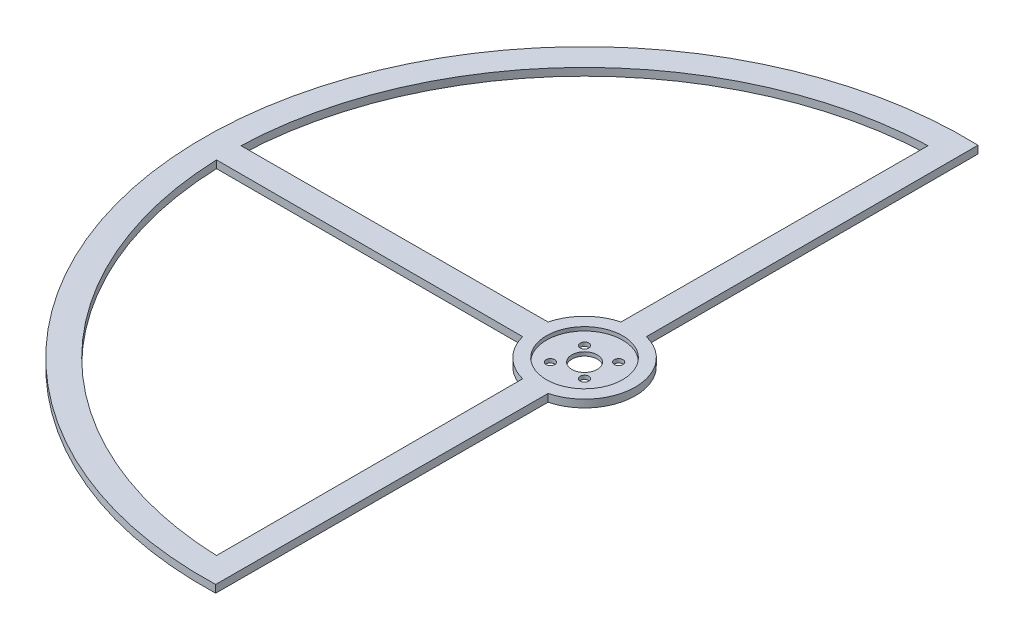
from build123d import *

# Parameters (mm, degrees)
SKETCH1_R           = 5
SKETCH1_R_2         = 1.7
BOSS_EXTRUDE1_DEPTH = 3
SKETCH2_R           = 15
CUT_EXTRUDE1_DEPTH  = 1.5


with BuildPart() as part:
    # Sketch1 → Boss-Extrude1 (new body)
    with BuildSketch(Plane(origin=(0, 0, 0), x_dir=(1, 0, 0), z_dir=(0, 1, 0))):
        with BuildLine():
            Line((5, -19.364916731), (4.6875, -149.926739922))
            ThreePointArc((4.6875, -149.926739922), (-149.999918535, 0.156331529), (5, 149.916643506))
            Line((5, 149.916643506), (5, 19.364916731))
            ThreePointArc((5, 19.364916731), (20, 0), (5, -19.364916731))
        make_face()
        Circle(SKETCH1_R, mode=Mode.SUBTRACT)
        with Locations((-5.656854249, 5.656854249)):
            Circle(SKETCH1_R_2, mode=Mode.SUBTRACT)
        with Locations((5.656854249, -5.656854249)):
            Circle(SKETCH1_R_2, mode=Mode.SUBTRACT)
        with Locations((6.717514421, 6.717514421)):
            Circle(SKETCH1_R_2, mode=Mode.SUBTRACT)
        with Locations((-6.717514421, -6.717514421)):
            Circle(SKETCH1_R_2, mode=Mode.SUBTRACT)
        with BuildLine():
            Line((-5, -19.364916731), (-5, -139.910685796))
            ThreePointArc((-5, -139.910685796), (-98.994949366, -98.994949366), (-139.910685796, -5))
            Line((-139.910685796, -5), (-19.364916731, -5))
            ThreePointArc((-19.364916731, -5), (-14.142135624, -14.142135624), (-5, -19.364916731))
        make_face(mode=Mode.SUBTRACT)
        with BuildLine():
            Line((-5, 19.364916731), (-4.666666667, 139.922200605))
            ThreePointArc((-4.666666667, 139.922200605), (-98.994949366, 98.994949366), (-139.922200605, 4.666666667))
            Line((-139.922200605, 4.666666667), (-19.364916731, 5))
            ThreePointArc((-19.364916731, 5), (-14.142135624, 14.142135624), (-5, 19.364916731))
        make_face(mode=Mode.SUBTRACT)
    extrude(amount=BOSS_EXTRUDE1_DEPTH)

    # Sketch2 → Cut-Extrude1 (cut)
    with BuildSketch(Plane(origin=(0, 3, 0), x_dir=(1, 0, 0), z_dir=(0, 1, 0))):
        Circle(SKETCH2_R)
    extrude(amount=-CUT_EXTRUDE1_DEPTH, mode=Mode.SUBTRACT)


solid = part.part
